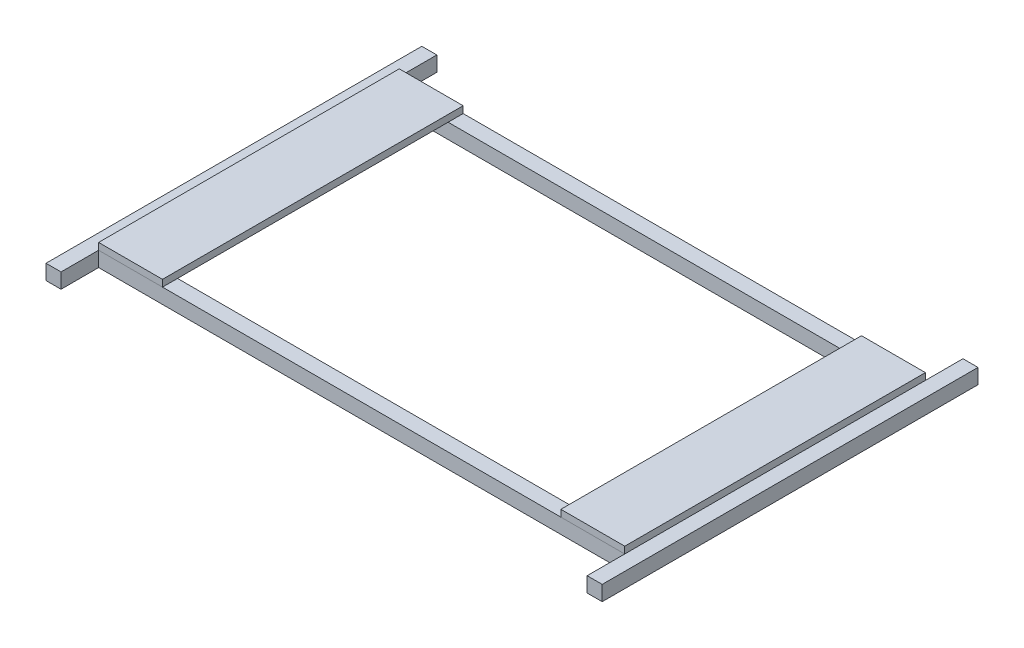
from build123d import *

# Parameters (mm, degrees)
SKETCH1_W             = 700
SKETCH1_H             = 20
SKETCH1_W_2           = 20
SKETCH1_H_2           = 50
SKETCH1_H_3           = 360
BOSS_EXTRUDE1_DEPTH   = 20
SKETCH3_W             = 85
SKETCH3_H             = 400
BOSS_EXTRUDE5_DEPTH   = 9
BOSS_EXTRUDE5_2_DEPTH = 9


with BuildPart() as part:
    # Sketch1 → Boss-Extrude1 (new body)
    with BuildSketch(Plane(origin=(0, 0, 0), x_dir=(1, 0, 0), z_dir=(0, 1, 0))):
        with Locations((15.272669909, 400.320607763)):
            Rectangle(SKETCH1_W, SKETCH1_H)
        Polygon((-354.727330091, 30.320607763), (-334.727330091, 30.320607763), (-334.727330091, 390.320607763), (-354.727330091, 390.320607763), (-354.727330091, 225.794194933), align=None)
        with Locations((-344.727330091, -14.679392237)):
            Rectangle(SKETCH1_W_2, SKETCH1_H_2)
        with Locations((-344.727330091, 20.320607763)):
            Rectangle(SKETCH1_W_2, SKETCH1_H)
        with Locations((15.272669909, 20.320607763)):
            Rectangle(SKETCH1_W, SKETCH1_H)
        with Locations((375.272669909, -14.679392237)):
            Rectangle(SKETCH1_W_2, SKETCH1_H_2)
        with Locations((375.272669909, 20.320607763)):
            Rectangle(SKETCH1_W_2, SKETCH1_H)
        with Locations((375.272669909, 210.320607763)):
            Rectangle(SKETCH1_W_2, SKETCH1_H_3)
        with Locations((375.272669909, 400.320607763)):
            Rectangle(SKETCH1_W_2, SKETCH1_H)
        with Locations((375.272669909, 435.320607763)):
            Rectangle(SKETCH1_W_2, SKETCH1_H_2)
        with Locations((-344.727330091, 435.320607763)):
            Rectangle(SKETCH1_W_2, SKETCH1_H_2)
        with Locations((-344.727330091, 400.320607763)):
            Rectangle(SKETCH1_W_2, SKETCH1_H)
    extrude(amount=-BOSS_EXTRUDE1_DEPTH)


with BuildPart() as body_2:
    # Sketch3 → Boss-Extrude5 (new body)
    with BuildSketch(Plane(origin=(0, 0, 0), x_dir=(1, 0, 0), z_dir=(0, 1, 0))):
        with Locations((-292.227330091, 210.320607763)):
            Rectangle(SKETCH3_W, SKETCH3_H)
    extrude(amount=BOSS_EXTRUDE5_DEPTH)


with BuildPart() as body_3:
    # Sketch3 → Boss-Extrude5 2 (new body)
    with BuildSketch(Plane(origin=(0, 0, 0), x_dir=(1, 0, 0), z_dir=(0, 1, 0))):
        with Locations((322.772669909, 210.320607763)):
            Rectangle(SKETCH3_W, SKETCH3_H)
    extrude(amount=BOSS_EXTRUDE5_2_DEPTH)


solid = Compound([part.part, body_2.part, body_3.part])
